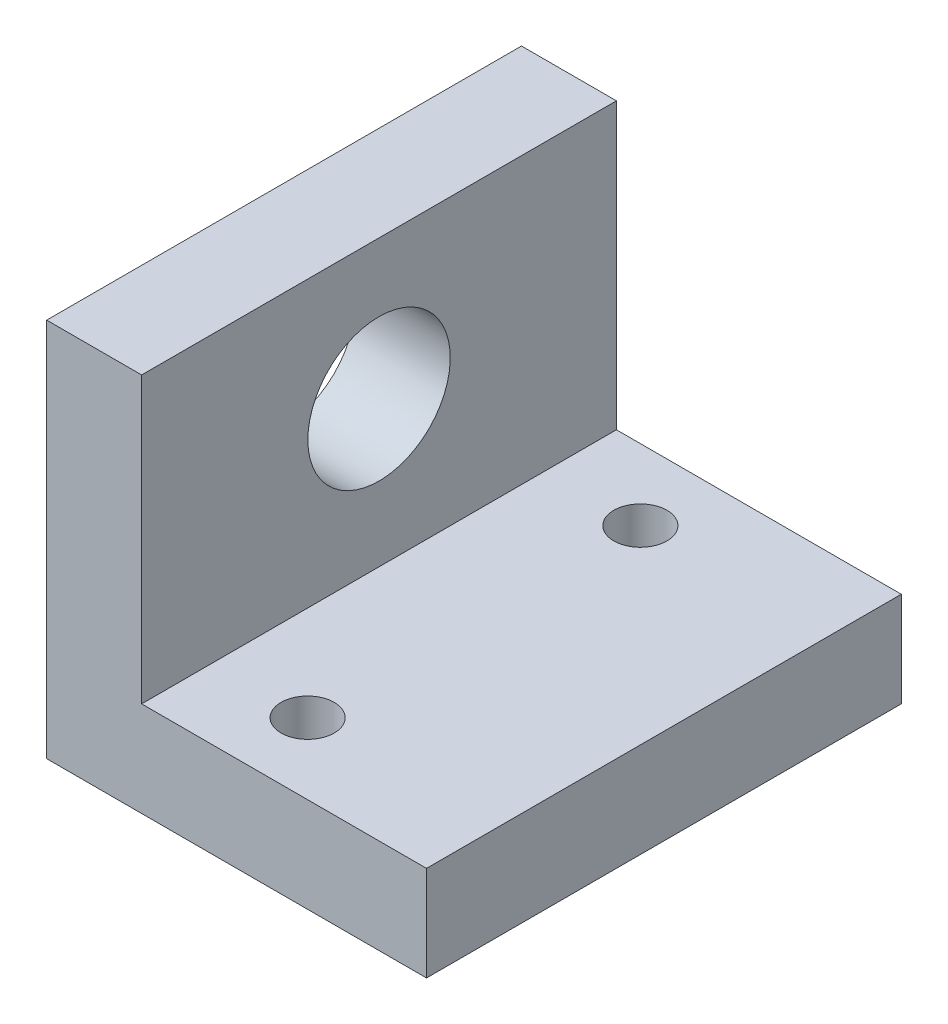
from build123d import *

# Parameters (mm, degrees)
BOSS_EXTRUDE1_DEPTH = 31.75
SKETCH2_R           = 4.7625
CUT_EXTRUDE1_DEPTH  = 26.4
SKETCH3_R           = 1.778
CUT_EXTRUDE2_DEPTH  = 7.35


with BuildPart() as part:
    # Sketch1 → Boss-Extrude1 (new body)
    with BuildSketch(Plane.XY):
        Polygon((0, 0), (0, 25.4), (6.35, 25.4), (6.35, 6.35), (25.4, 6.35), (25.4, 0), align=None)
    extrude(amount=-BOSS_EXTRUDE1_DEPTH)

    # Sketch2 → Cut-Extrude1 (cut, through all)
    with BuildSketch(Plane.ZY):
        with Locations((-15.875, 16.0782)):
            Circle(SKETCH2_R)
    extrude(amount=-CUT_EXTRUDE1_DEPTH, mode=Mode.SUBTRACT)

    # Sketch3 → Cut-Extrude2 (cut, through all)
    with BuildSketch(Plane(origin=(0, 6.35, 0), x_dir=(1, 0, 0), z_dir=(0, 1, 0))):
        with Locations((12.7, 27.0002)):
            Circle(SKETCH3_R)
        with Locations((12.7, 4.7498)):
            Circle(SKETCH3_R)
    extrude(amount=-CUT_EXTRUDE2_DEPTH, mode=Mode.SUBTRACT)


solid = part.part
